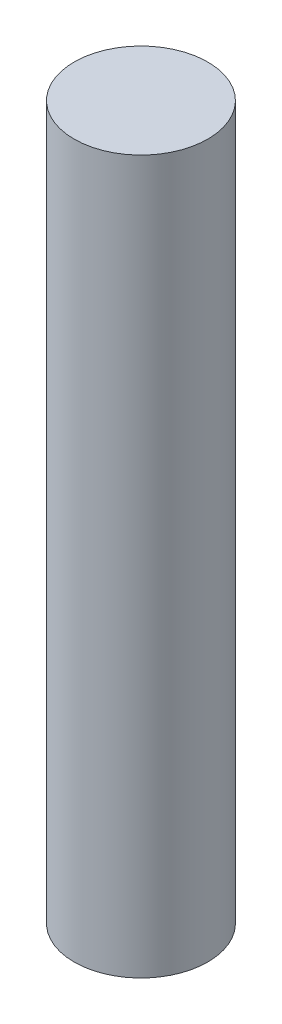
from build123d import *

# Parameters (mm, degrees)
SKETCH1_R           = 2.38125
BOSS_EXTRUDE1_DEPTH = 25.4


with BuildPart() as part:
    # Sketch1 → Boss-Extrude1 (new body)
    with BuildSketch(Plane(origin=(0, 0, 0), x_dir=(1, 0, 0), z_dir=(0, 1, 0))):
        Circle(SKETCH1_R)
    extrude(amount=BOSS_EXTRUDE1_DEPTH)


solid = part.part
